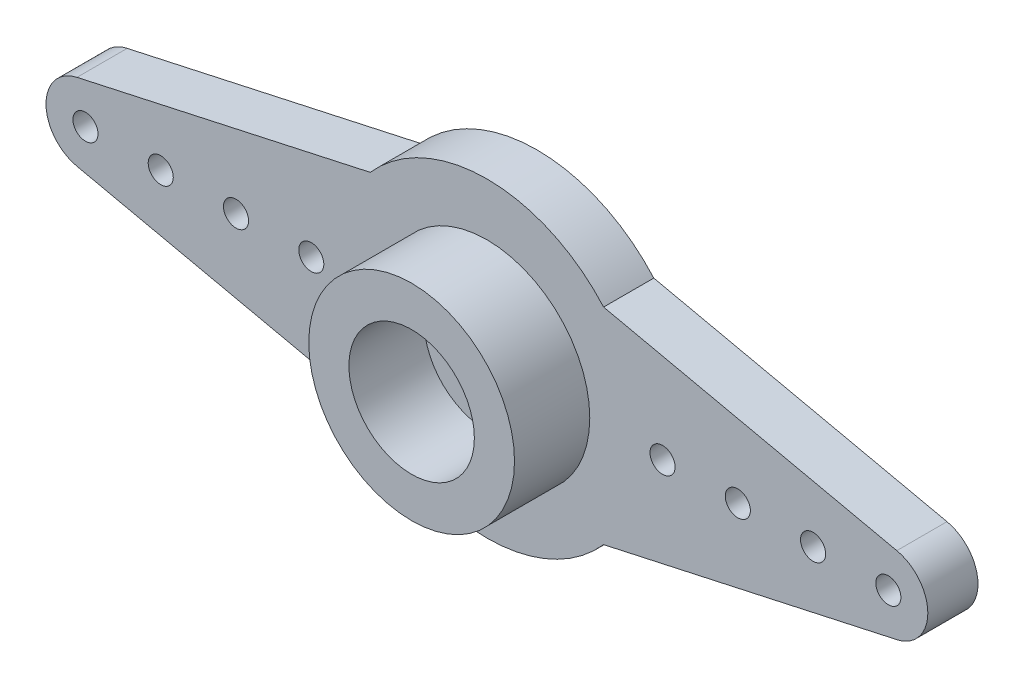
from build123d import *

# Parameters (mm, degrees)
ESQUISSE1_R        = 1.5
ESQUISSE1_R_2      = 0.5
BOSS_EXTRU_1_DEPTH = 2
ESQUISSE2_R        = 4.1
ESQUISSE2_R_2      = 2.5
BOSS_EXTRU_2_DEPTH = 3


with BuildPart() as part:
    # Esquisse1 → Boss.-Extru.1 (new body)
    with BuildSketch(Plane.XY):
        with BuildLine():
            Line((-16.337044695, 1.536467752), (-4.650806382, 4.1))
            ThreePointArc((-4.650806382, 4.1), (0, 6.2), (4.650806382, 4.1))
            Line((4.650806382, 4.1), (16.337044695, 1.536467752))
            ThreePointArc((16.337044695, 1.536467752), (17.573001042, 0), (16.337044695, -1.536467752))
            Line((16.337044695, -1.536467752), (4.650806382, -4.1))
            ThreePointArc((4.650806382, -4.1), (0, -6.2), (-4.650806382, -4.1))
            Line((-4.650806382, -4.1), (-16.337044695, -1.536467752))
            ThreePointArc((-16.337044695, -1.536467752), (-17.573001042, 0), (-16.337044695, 1.536467752))
        make_face()
        Circle(ESQUISSE1_R, mode=Mode.SUBTRACT)
        with Locations((7, 0)):
            Circle(ESQUISSE1_R_2, mode=Mode.SUBTRACT)
        with Locations((16, 0)):
            Circle(ESQUISSE1_R_2, mode=Mode.SUBTRACT)
        with Locations((13, 0)):
            Circle(ESQUISSE1_R_2, mode=Mode.SUBTRACT)
        with Locations((10, 0)):
            Circle(ESQUISSE1_R_2, mode=Mode.SUBTRACT)
        with Locations((-16, 0)):
            Circle(ESQUISSE1_R_2, mode=Mode.SUBTRACT)
        with Locations((-13, 0)):
            Circle(ESQUISSE1_R_2, mode=Mode.SUBTRACT)
        with Locations((-10, 0)):
            Circle(ESQUISSE1_R_2, mode=Mode.SUBTRACT)
        with Locations((-7, 0)):
            Circle(ESQUISSE1_R_2, mode=Mode.SUBTRACT)
    extrude(amount=BOSS_EXTRU_1_DEPTH)

    # Esquisse2 → Boss.-Extru.2 (add)
    with BuildSketch(Plane.XY.offset(2)):
        Circle(ESQUISSE2_R)
        Circle(ESQUISSE2_R_2, mode=Mode.SUBTRACT)
    extrude(amount=BOSS_EXTRU_2_DEPTH)


solid = part.part
